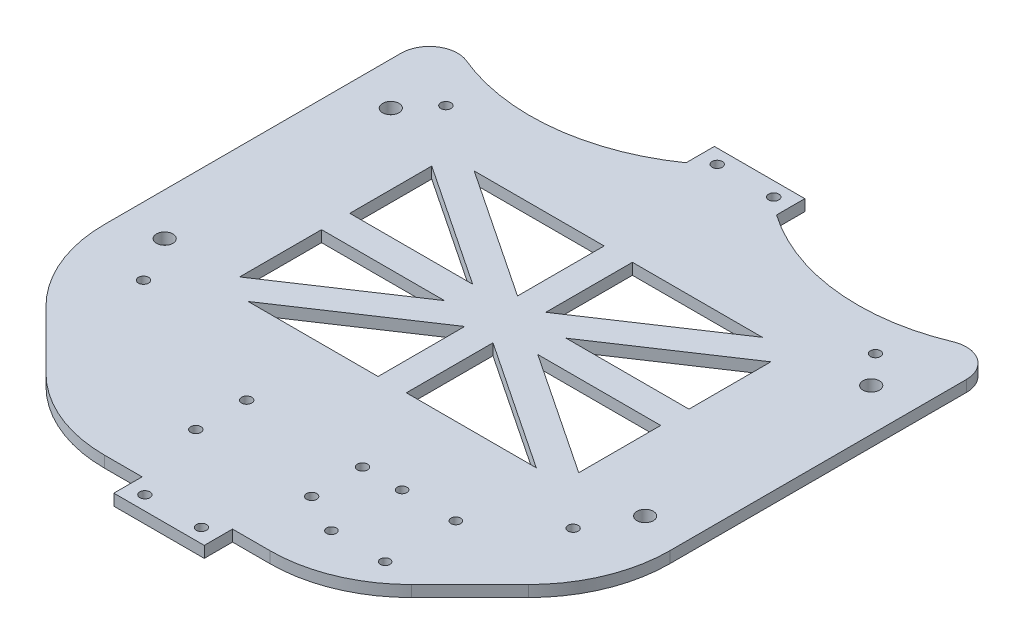
from build123d import *

# Parameters (mm, degrees)
BOSS_EXTRUDE1_DEPTH      = 4
M5_CLEARANCE_HOLE1_D     = 5.8
FILLET1_R                = 10
M3_CLEARANCE_HOLE1_D     = 3.6
M3_CLEARANCE_HOLE1_DEPTH = 10
M3_CLEARANCE_HOLE1_TIP   = 1.081549114
CHAMFER1_SIZE            = 50
FILLET3_R                = 50
M3_CLEARANCE_HOLE2_D     = 3.6
M3_CLEARANCE_HOLE3_D     = 3.4


with BuildPart() as part:
    # Sketch1 → Boss-Extrude1 (new body)
    with BuildSketch(Plane(origin=(0, 0, 0), x_dir=(1, 0, 0), z_dir=(0, 1, 0))):
        with BuildLine():
            Line((-100, -29.5), (-100, -222))
            Line((-100, -222), (-16, -222))
            Line((-16, -222), (-16, -232))
            Line((-16, -232), (16, -232))
            Line((16, -232), (16, -222))
            Line((16, -222), (100, -222))
            Line((100, -222), (100, -29.5))
            ThreePointArc((100, -29.5), (58, -42.739333694), (16, -29.5))
            Line((16, -29.5), (16, -19.5))
            Line((16, -19.5), (-16, -19.5))
            Line((-16, -19.5), (-16, -29.5))
            ThreePointArc((-16, -29.5), (-58, -42.739333694), (-100, -29.5))
        make_face()
        Polygon((-50.986121811, -69.5), (-5, -69.5), (-5, -100.157414541), align=None, mode=Mode.SUBTRACT)
        Polygon((5, -69.5), (50.986121811, -69.5), (5, -100.157414541), align=None, mode=Mode.SUBTRACT)
        Polygon((60, -75.509252126), (60, -104.5), (16.513878189, -104.5), align=None, mode=Mode.SUBTRACT)
        Polygon((60, -114.5), (60, -143.490747874), (16.513878189, -114.5), align=None, mode=Mode.SUBTRACT)
        Polygon((50.986121811, -149.5), (5, -149.5), (5, -118.842585459), align=None, mode=Mode.SUBTRACT)
        Polygon((-5, -149.5), (-50.986121811, -149.5), (-5, -118.842585459), align=None, mode=Mode.SUBTRACT)
        Polygon((-60, -143.490747874), (-60, -114.5), (-16.513878189, -114.5), align=None, mode=Mode.SUBTRACT)
        Polygon((-16.513878189, -104.5), (-60, -104.5), (-60, -75.509252126), align=None, mode=Mode.SUBTRACT)
    extrude(amount=BOSS_EXTRUDE1_DEPTH)

    # M5 Clearance Hole1 (through all)
    with Locations(Plane(origin=(0, 4, 0), x_dir=(1, 0, 0), z_dir=(0, 1, 0))):
        with Locations((-85, -65), (-85, -145), (85, -145), (85, -65)):
            Hole(M5_CLEARANCE_HOLE1_D / 2)

    # Fillet1
    fillet1_edges = [part.edges().sort_by_distance(p)[0] for p in [
        (100, 2, 29.5),
        (-100, 2, 29.5),
    ]]
    fillet(fillet1_edges, radius=FILLET1_R)

    # M3 Clearance Hole1
    with Locations(Plane(origin=(0, 4, 0), x_dir=(1, 0, 0), z_dir=(0, 1, 0))):
        with Locations((-21, -198), (-21, -180), (20, -180), (20, -198)):
            Hole(M3_CLEARANCE_HOLE1_D / 2, depth=M3_CLEARANCE_HOLE1_DEPTH)
            with Locations((0, 0, -(M3_CLEARANCE_HOLE1_DEPTH + M3_CLEARANCE_HOLE1_TIP / 2))):  # 118° drill point
                Cone(0, M3_CLEARANCE_HOLE1_D / 2, M3_CLEARANCE_HOLE1_TIP, mode=Mode.SUBTRACT)

    # Chamfer1
    chamfer1_edges = [part.edges().sort_by_distance(p)[0] for p in [
        (100, 2, 222),
        (-100, 2, 222),
    ]]
    chamfer(chamfer1_edges, length=CHAMFER1_SIZE)

    # Fillet3
    fillet3_edges = [part.edges().sort_by_distance(p)[0] for p in [
        (100, 2, 172),
        (50, 2, 222),
        (-50, 2, 222),
        (-100, 2, 172),
    ]]
    fillet(fillet3_edges, radius=FILLET3_R)

    # M3 Clearance Hole2 (through all)
    with Locations(Plane(origin=(0, 4, 0), x_dir=(1, 0, 0), z_dir=(0, 1, 0))):
        with Locations((-76, -54.5), (76, -54.5), (76, -161.5), (-76, -161.5), (-10, -24.5), (10, -24.5), (-10, -227), (10, -227)):
            Hole(M3_CLEARANCE_HOLE2_D / 2)

    # M3 Clearance Hole3 (through all)
    with Locations(Plane(origin=(0, 4, 0), x_dir=(1, 0, 0), z_dir=(0, 1, 0))):
        with Locations((53, -180), (34, -180), (34, -205), (53, -205)):
            Hole(M3_CLEARANCE_HOLE3_D / 2)


solid = part.part
